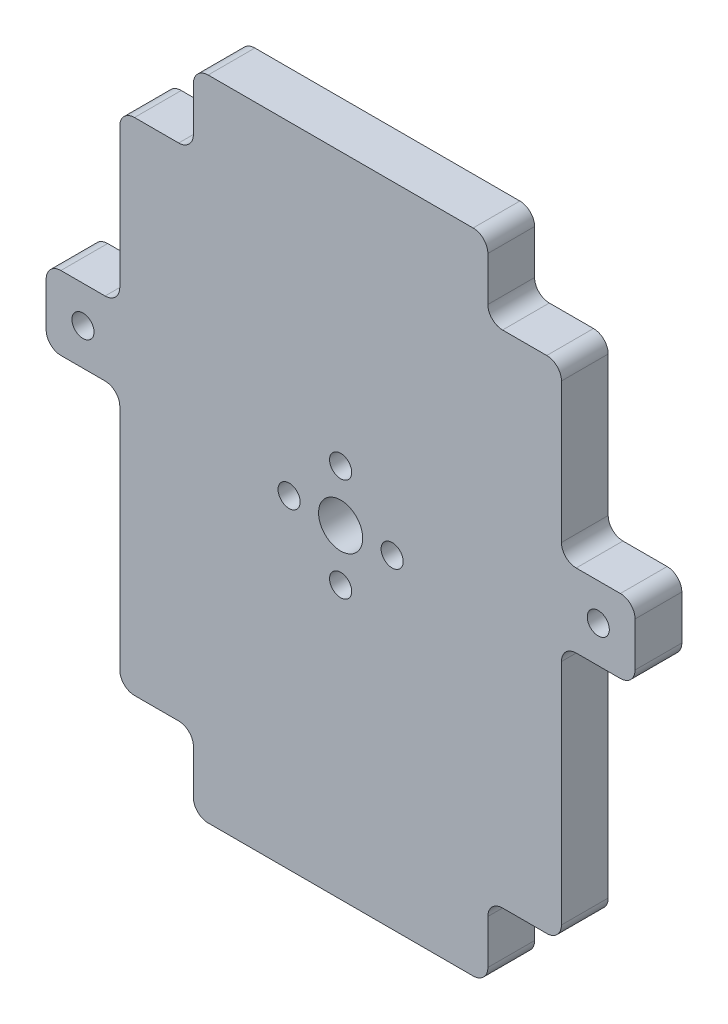
from build123d import *

# Parameters (mm, degrees)
EXTRUDE_1_DEPTH     = 6.35
SKETCH_2_R          = 1.5
CUT_EXTRUDE_1_DEPTH = 7.35
SKETCH_3_R          = 3
SKETCH_3_R_2        = 1.5
CUT_EXTRUDE_2_DEPTH = 7.35


with BuildPart() as part:
    # 草图1 → 凸台-拉伸1 (new body)
    with BuildSketch(Plane.XY):
        with BuildLine():
            Line((-28.036772487, 40.483201058), (-28.036772487, 21.483201058))
            ThreePointArc((-28.036772487, 21.483201058), (-28.622558924, 20.068987496), (-30.036772487, 19.483201058))
            Line((-30.036772487, 19.483201058), (-36.036772487, 19.483201058))
            ThreePointArc((-36.036772487, 19.483201058), (-37.450986049, 18.897414621), (-38.036772487, 17.483201058))
            Line((-38.036772487, 17.483201058), (-38.036772487, 11.483201058))
            ThreePointArc((-38.036772487, 11.483201058), (-37.450986049, 10.068987496), (-36.036772487, 9.483201058))
            Line((-36.036772487, 9.483201058), (-30.036772487, 9.483201058))
            ThreePointArc((-30.036772487, 9.483201058), (-28.622558924, 8.897414621), (-28.036772487, 7.483201058))
            Line((-28.036772487, 7.483201058), (-28.036772487, -23.516798942))
            ThreePointArc((-28.036772487, -23.516798942), (-27.450986049, -24.931012504), (-26.036772487, -25.516798942))
            Line((-26.036772487, -25.516798942), (-20.036772487, -25.516798942))
            ThreePointArc((-20.036772487, -25.516798942), (-18.622558924, -26.102585379), (-18.036772487, -27.516798942))
            Line((-18.036772487, -27.516798942), (-18.036772487, -33.516798942))
            ThreePointArc((-18.036772487, -33.516798942), (-17.450986049, -34.931012504), (-16.036772487, -35.516798942))
            Line((-16.036772487, -35.516798942), (19.963227513, -35.516798942))
            ThreePointArc((19.963227513, -35.516798942), (21.377441076, -34.931012504), (21.963227513, -33.516798942))
            Line((21.963227513, -33.516798942), (21.963227513, -27.516798942))
            ThreePointArc((21.963227513, -27.516798942), (22.549013951, -26.102585379), (23.963227513, -25.516798942))
            Line((23.963227513, -25.516798942), (29.963227513, -25.516798942))
            ThreePointArc((29.963227513, -25.516798942), (31.377441076, -24.931012504), (31.963227513, -23.516798942))
            Line((31.963227513, -23.516798942), (31.963227513, 7.483201058))
            ThreePointArc((31.963227513, 7.483201058), (32.549013951, 8.897414621), (33.963227513, 9.483201058))
            Line((33.963227513, 9.483201058), (39.963227513, 9.483201058))
            ThreePointArc((39.963227513, 9.483201058), (41.377441076, 10.068987496), (41.963227513, 11.483201058))
            Line((41.963227513, 11.483201058), (41.963227513, 17.483201058))
            ThreePointArc((41.963227513, 17.483201058), (41.377441076, 18.897414621), (39.963227513, 19.483201058))
            Line((39.963227513, 19.483201058), (33.963227513, 19.483201058))
            ThreePointArc((33.963227513, 19.483201058), (32.549013951, 20.068987496), (31.963227513, 21.483201058))
            Line((31.963227513, 21.483201058), (31.963227513, 40.483201058))
            ThreePointArc((31.963227513, 40.483201058), (31.377441076, 41.897414621), (29.963227513, 42.483201058))
            Line((29.963227513, 42.483201058), (23.963227513, 42.483201058))
            ThreePointArc((23.963227513, 42.483201058), (22.549013951, 43.068987496), (21.963227513, 44.483201058))
            Line((21.963227513, 44.483201058), (21.963227513, 50.483201058))
            ThreePointArc((21.963227513, 50.483201058), (21.377441076, 51.897414621), (19.963227513, 52.483201058))
            Line((19.963227513, 52.483201058), (-16.036772487, 52.483201058))
            ThreePointArc((-16.036772487, 52.483201058), (-17.450986049, 51.897414621), (-18.036772487, 50.483201058))
            Line((-18.036772487, 50.483201058), (-18.036772487, 44.483201058))
            ThreePointArc((-18.036772487, 44.483201058), (-18.622558924, 43.068987496), (-20.036772487, 42.483201058))
            Line((-20.036772487, 42.483201058), (-26.036772487, 42.483201058))
            ThreePointArc((-26.036772487, 42.483201058), (-27.450986049, 41.897414621), (-28.036772487, 40.483201058))
        make_face()
    extrude(amount=EXTRUDE_1_DEPTH)

    # 草图2 → 切除-拉伸1 (cut, through all)
    with BuildSketch(Plane.XY.offset(6.35)):
        with Locations((-33.036772487, 14.483201058)):
            Circle(SKETCH_2_R)
        with Locations((36.963227513, 14.483201058)):
            Circle(SKETCH_2_R)
    extrude(amount=-CUT_EXTRUDE_1_DEPTH, mode=Mode.SUBTRACT)

    # 草图3 → 切除-拉伸2 (cut, through all)
    with BuildSketch(Plane.XY.offset(6.35)):
        with Locations((1.963227513, 8.483201058)):
            Circle(SKETCH_3_R)
        with Locations((8.963227513, 8.483201058)):
            Circle(SKETCH_3_R_2)
        with Locations((1.963227513, 15.483201058)):
            Circle(SKETCH_3_R_2)
        with Locations((-5.036772487, 8.483201058)):
            Circle(SKETCH_3_R_2)
        with Locations((1.963227513, 1.483201058)):
            Circle(SKETCH_3_R_2)
    extrude(amount=-CUT_EXTRUDE_2_DEPTH, mode=Mode.SUBTRACT)


solid = part.part
